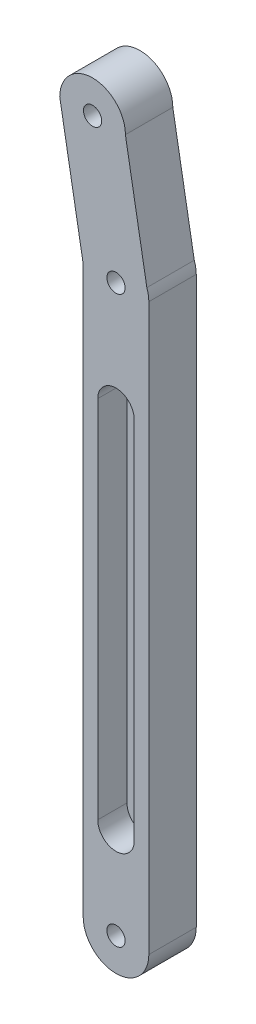
from build123d import *

# Parameters (mm, degrees)
SKETCH1_R      = 2.5
EXTRUDE1_DEPTH = 13
EXTRUDE2_DEPTH = 8


with BuildPart() as part:
    # Sketch1 → Extrude1 (new body)
    with BuildSketch(Plane.XY):
        with BuildLine():
            Line((-14.328597561, 112.637649389), (-14.328597561, -42.362350611))
            ThreePointArc((-14.328597561, -42.362350611), (-5.328597561, -51.362350611), (3.671402439, -42.362350611))
            Line((3.671402439, -42.362350611), (3.671402439, 112.637649389))
            ThreePointArc((3.671402439, 112.637649389), (3.534672216, 114.200482988), (3.128636026, 115.715830679))
            Line((3.128636026, 115.715830679), (-2.753580135, 149.07553625))
            ThreePointArc((-2.753580135, 149.07553625), (-11.753580135, 158.07553625), (-20.753580135, 149.07553625))
            Line((-20.753580135, 149.07553625), (-14.328597561, 112.637649389))
        make_face()
        with Locations((-5.328597561, 112.637649389)):
            Circle(SKETCH1_R, mode=Mode.SUBTRACT)
        with Locations((-5.328597561, -42.362350611)):
            Circle(SKETCH1_R, mode=Mode.SUBTRACT)
        with Locations((-11.753580135, 149.07553625)):
            Circle(SKETCH1_R, mode=Mode.SUBTRACT)
    extrude(amount=EXTRUDE1_DEPTH)

    # Sketch2 → Extrude2 (cut)
    with BuildSketch(Plane.XY.offset(13)):
        with BuildLine():
            Line((-0.328597561, 82.637649389), (-0.328597561, -17.362350611))
            ThreePointArc((-0.328597561, -17.362350611), (-5.328597561, -22.362350611), (-10.328597561, -17.362350611))
            Line((-10.328597561, -17.362350611), (-10.328597561, 82.637649389))
            ThreePointArc((-10.328597561, 82.637649389), (-5.328597561, 87.637649389), (-0.328597561, 82.637649389))
        make_face()
    extrude(amount=-EXTRUDE2_DEPTH, mode=Mode.SUBTRACT)


solid = part.part
